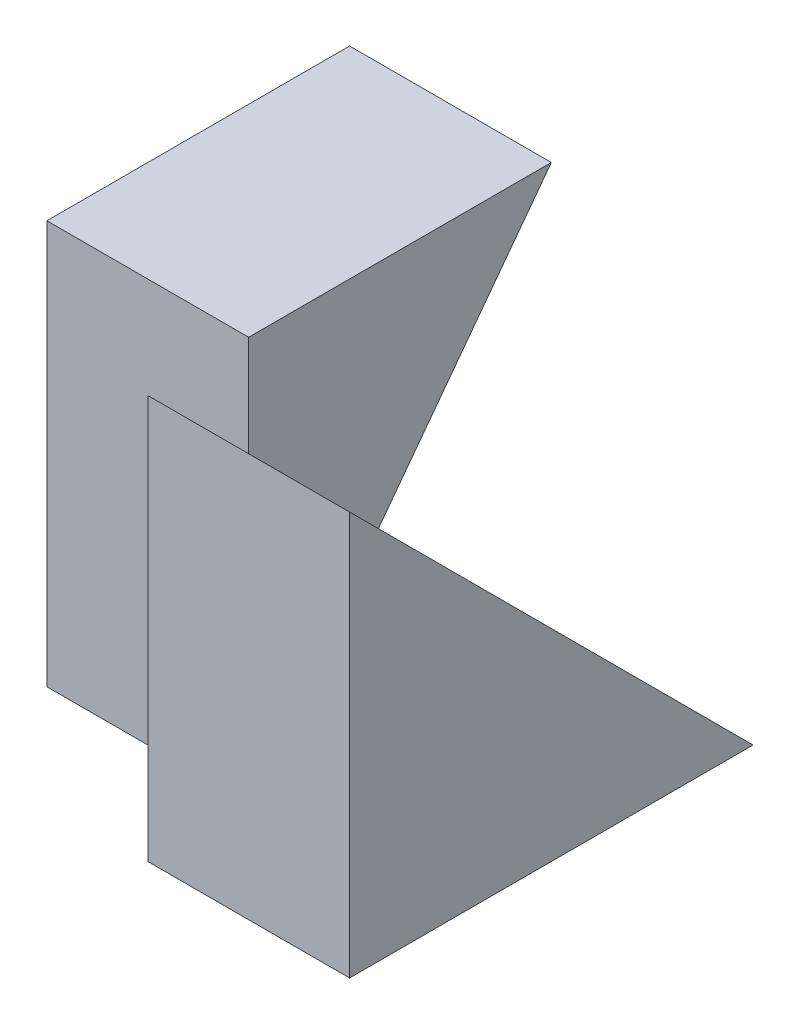
from build123d import *

# Parameters (mm, degrees)
SKETCH1_W           = 4
SKETCH1_H           = 4
BOSS_EXTRUDE1_DEPTH = 2
SKETCH2_W           = 3
SKETCH2_H           = 4
BOSS_EXTRUDE2_DEPTH = 2
CUT_EXTRUDE1_DEPTH  = 2
CUT_EXTRUDE2_DEPTH  = 2


with BuildPart() as part:
    # Sketch1 → Boss-Extrude1 (new body)
    with BuildSketch(Plane(origin=(0, 0, 0), x_dir=(0, 0, -1), z_dir=(1, 0, 0))):
        with Locations((2, 2)):
            Rectangle(SKETCH1_W, SKETCH1_H)
    extrude(amount=BOSS_EXTRUDE1_DEPTH)

    # Sketch2 → Boss-Extrude2 (add)
    with BuildSketch(Plane.ZY):
        with Locations((-2.5, 2)):
            Rectangle(SKETCH2_W, SKETCH2_H)
    extrude(amount=BOSS_EXTRUDE2_DEPTH)

    # Sketch3 → Cut-Extrude1 (cut)
    with BuildSketch(Plane(origin=(2, 0, 0), x_dir=(0, 0, -1), z_dir=(1, 0, 0))):
        Polygon((4, 0), (0, 4), (4, 4), align=None)
    extrude(amount=-CUT_EXTRUDE1_DEPTH, mode=Mode.SUBTRACT)

    # Sketch4 → Cut-Extrude2 (cut)
    with BuildSketch(Plane.ZY.offset(2)):
        Polygon((-1, 0), (-4, 4), (-4, 0), align=None)
    extrude(amount=-CUT_EXTRUDE2_DEPTH, mode=Mode.SUBTRACT)


solid = part.part
